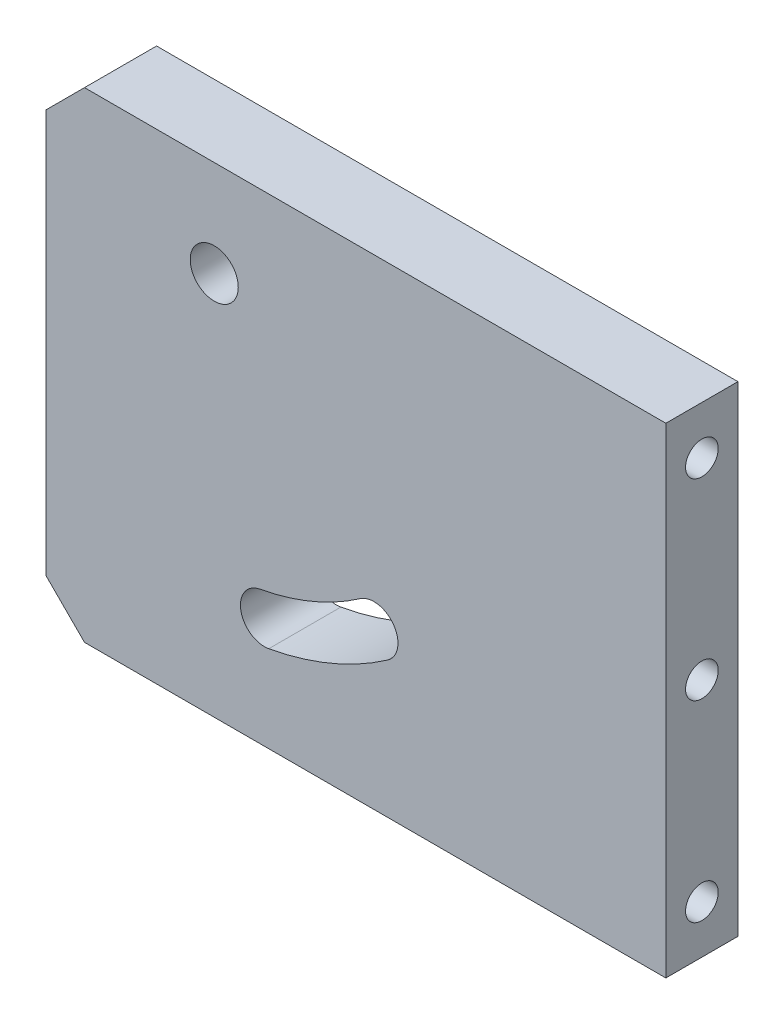
from build123d import *

# Parameters (mm, degrees)
CROQUIS1_R                = 5
SALIENTE_EXTRUIR1_DEPTH   = 15
TALADRO_ROSCADO_M81_D     = 6.8
TALADRO_ROSCADO_M81_DEPTH = 20
TALADRO_ROSCADO_M81_TIP   = 2.042926105


with BuildPart() as part:
    # Croquis1 → Saliente-Extruir1 (new body)
    with BuildSketch(Plane.XY):
        Polygon((-64.5, 42), (-56.5, 50), (64.5, 50), (64.5, -50), (-56.5, -50), (-64.5, -42), align=None)
        with Locations((-29.5, 30)):
            Circle(CROQUIS1_R, mode=Mode.SUBTRACT)
        with BuildLine():
            ThreePointArc((-18.148924408, -31.968968709), (-5.213281237, -28.130502249), (6.608289397, -21.625492122))
            ThreePointArc((6.608289397, -21.625492122), (7.839813422, -14.662493589), (0.876814889, -13.430969563))
            ThreePointArc((0.876814889, -13.430969563), (-9.068315962, -18.9034384), (-19.950682438, -22.13262447))
            ThreePointArc((-19.950682438, -22.13262447), (-23.967975543, -27.951675605), (-18.148924408, -31.968968709))
        make_face(mode=Mode.SUBTRACT)
    extrude(amount=SALIENTE_EXTRUIR1_DEPTH)

    # Taladro roscado M81
    with Locations(Plane(origin=(64.5, 0, 0), x_dir=(0, 0, -1), z_dir=(1, 0, 0))):
        with Locations((-7.5, 40), (-7.5, 0), (-7.5, -40)):
            Hole(TALADRO_ROSCADO_M81_D / 2, depth=TALADRO_ROSCADO_M81_DEPTH)
            with Locations((0, 0, -(TALADRO_ROSCADO_M81_DEPTH + TALADRO_ROSCADO_M81_TIP / 2))):  # 118° drill point
                Cone(0, TALADRO_ROSCADO_M81_D / 2, TALADRO_ROSCADO_M81_TIP, mode=Mode.SUBTRACT)


solid = part.part
